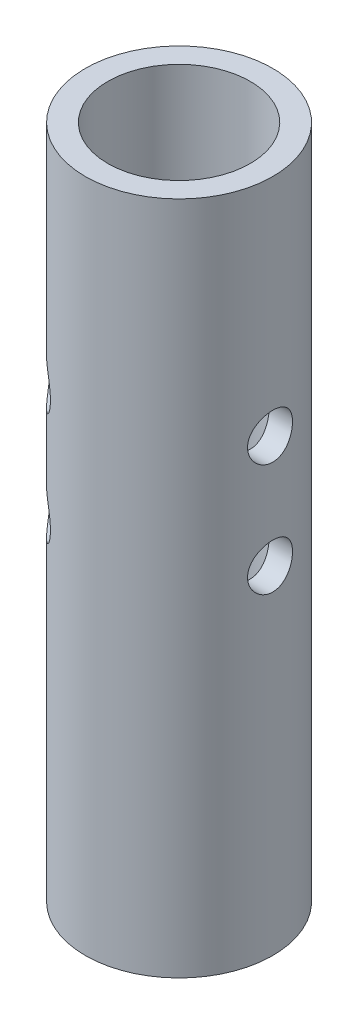
from build123d import *

# Parameters (mm, degrees)
SKETCH2_R           = 12.5
SKETCH2_R_2         = 9.5
BOSS_EXTRUDE1_DEPTH = 90
SKETCH4_R           = 3
CUT_EXTRUDE1_DEPTH  = 10
SKETCH5_R           = 3
CUT_EXTRUDE2_DEPTH  = 10


with BuildPart() as part:
    # Sketch2 → Boss-Extrude1 (new body)
    with BuildSketch(Plane(origin=(0, 0, 0), x_dir=(1, 0, 0), z_dir=(0, 1, 0))):
        Circle(SKETCH2_R)
        Circle(SKETCH2_R_2, mode=Mode.SUBTRACT)
    extrude(amount=BOSS_EXTRUDE1_DEPTH)

    # Sketch4 → Cut-Extrude1 (cut)
    with BuildSketch(Plane(origin=(12.5, 0, 0), x_dir=(0, 0, -1), z_dir=(1, 0, 0))):
        with Locations((0, 60)):
            Circle(SKETCH4_R)
        with Locations((0, 45)):
            Circle(SKETCH4_R)
    extrude(amount=-CUT_EXTRUDE1_DEPTH, mode=Mode.SUBTRACT)

    # Sketch5 → Cut-Extrude2 (cut)
    with BuildSketch(Plane(origin=(-8.838834765, 0, -8.838834765), x_dir=(-0.707106781, 0, 0.707106781), z_dir=(-0.707106781, 0, -0.707106781))):
        with Locations((0, 60)):
            Circle(SKETCH5_R)
        with Locations((0, 45)):
            Circle(SKETCH5_R)
    cut_extrude2 = extrude(amount=-CUT_EXTRUDE2_DEPTH, mode=Mode.SUBTRACT)

    # Mirror1: Cut-Extrude2 across plane
    add(cut_extrude2.mirror(Plane.XY), mode=Mode.SUBTRACT)


solid = part.part
